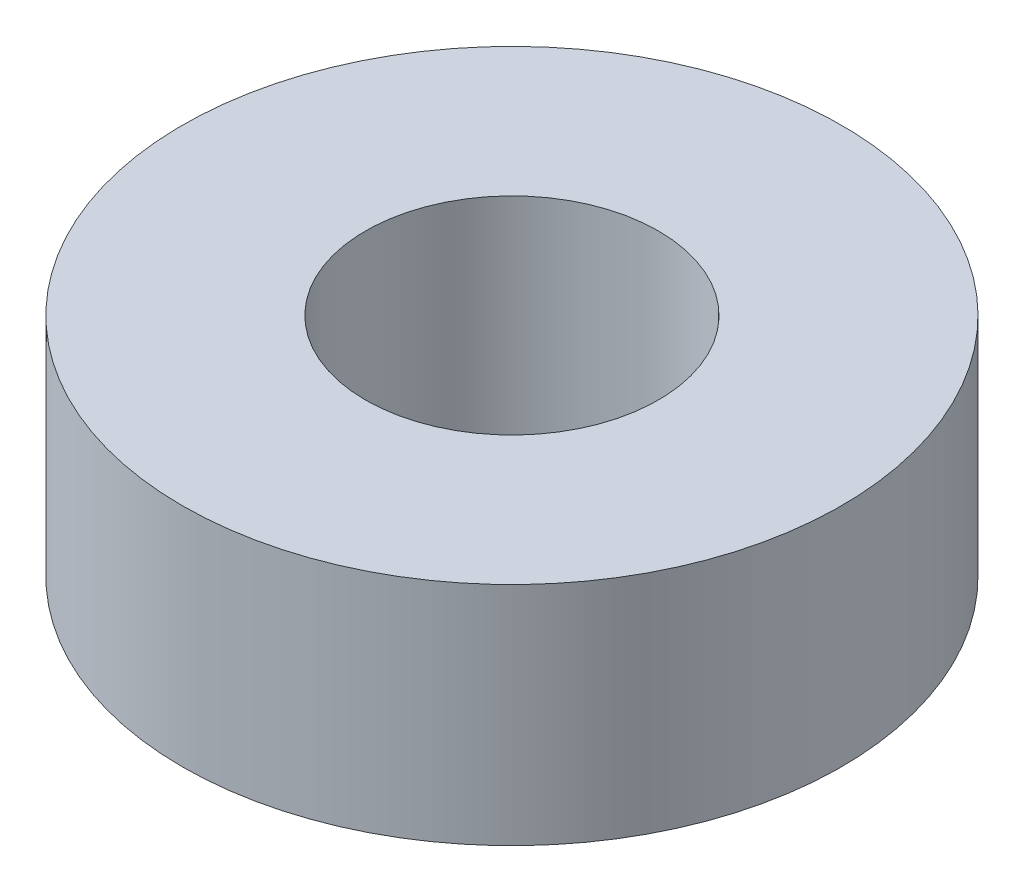
from build123d import *

# Parameters (mm, degrees)
SKETCH1_R      = 7.14375
SKETCH1_R_2    = 3.175
EXTRUDE1_DEPTH = 4.9022


with BuildPart() as part:
    # Sketch1 → Extrude1 (new body)
    with BuildSketch(Plane(origin=(0, 0, 0), x_dir=(1, 0, 0), z_dir=(0, 1, 0))):
        Circle(SKETCH1_R)
        Circle(SKETCH1_R_2, mode=Mode.SUBTRACT)
    extrude(amount=EXTRUDE1_DEPTH)


solid = part.part
